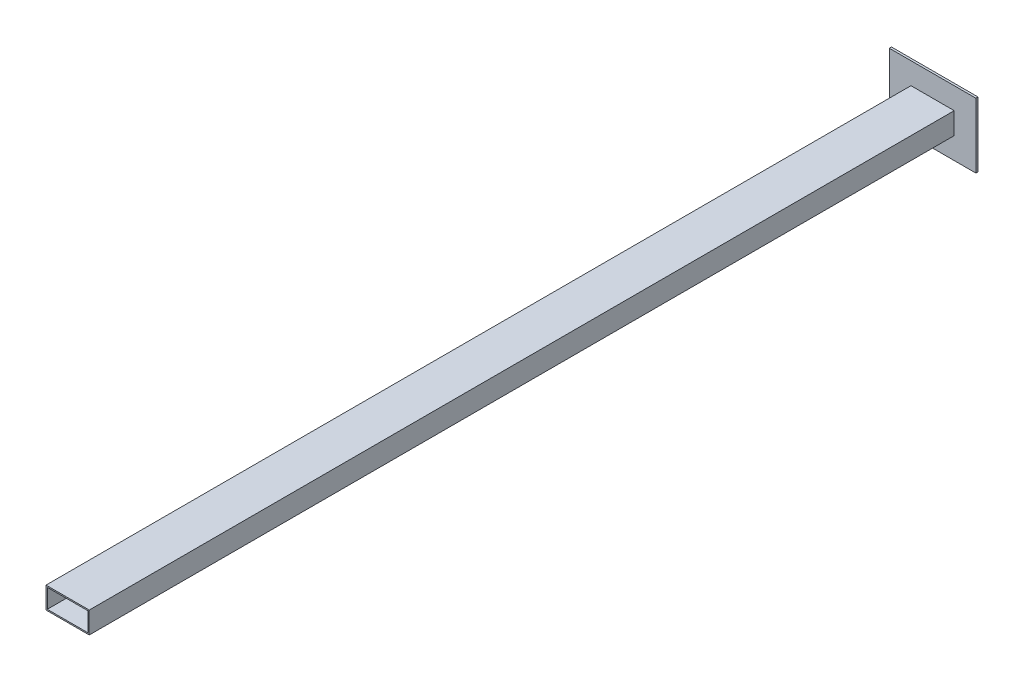
from build123d import *

# Parameters (mm, degrees)
SKETCH1_W              = 100
SKETCH1_H              = 50
SKETCH1_W_2            = 94
SKETCH1_H_2            = 44
BOSS_EXTRUDE1_DEPTH    = 2000
SKETCH2_W              = 200
SKETCH2_H              = 150
BOSS_EXTRUDE2_DEPTH    = 5
SPLIT2_SURFACE_1_BACK  = 2021.526
SPLIT2_SURFACE_1_DEPTH = 4043.052
SPLIT2_SURFACE_2_BACK  = 2021.526
SPLIT2_SURFACE_2_DEPTH = 4043.052


with BuildPart() as part:
    # Sketch1 → Boss-Extrude1 (new body)
    with BuildSketch(Plane.XY):
        with Locations((50, 25)):
            Rectangle(SKETCH1_W, SKETCH1_H)
        with Locations((50, 25)):
            Rectangle(SKETCH1_W_2, SKETCH1_H_2, mode=Mode.SUBTRACT)
    extrude(amount=BOSS_EXTRUDE1_DEPTH)

    # Sketch2 → Boss-Extrude2 (add)
    with BuildSketch(Plane(origin=(0, 0, 0), x_dir=(-1, 0, 0), z_dir=(0, 0, -1))):
        with Locations((-50, 25)):
            Rectangle(SKETCH2_W, SKETCH2_H)
    extrude(amount=BOSS_EXTRUDE2_DEPTH)


with BuildPart() as body_2:
    # Split2: the piece behind the surface
    add(part.part)
    # Split2 surface: a surface, the sketch's curves swept straight by 4043.052 mm
    with BuildLine(Plane.XZ.offset(-SPLIT2_SURFACE_1_BACK), mode=Mode.PRIVATE) as split2_surface_1_path:
        Line((-60.263801814, 0), (177.114806947, 0))
    split2_surface_1 = Shell.extrude(split2_surface_1_path.wire(), (0 * SPLIT2_SURFACE_1_DEPTH, -1 * SPLIT2_SURFACE_1_DEPTH, 0 * SPLIT2_SURFACE_1_DEPTH))
    split(bisect_by=split2_surface_1, keep=Keep.BOTTOM)


with BuildPart() as part_1:
    add(part.part)

    # Split2: split by a surface, the side it looks to stays
    # Split2 surface: a surface, the sketch's curves swept straight by 4043.052 mm
    with BuildLine(Plane.XZ.offset(-SPLIT2_SURFACE_2_BACK), mode=Mode.PRIVATE) as split2_surface_2_path:
        Line((-60.263801814, 0), (177.114806947, 0))
    split2_surface_2 = Shell.extrude(split2_surface_2_path.wire(), (0 * SPLIT2_SURFACE_2_DEPTH, -1 * SPLIT2_SURFACE_2_DEPTH, 0 * SPLIT2_SURFACE_2_DEPTH))
    split(bisect_by=split2_surface_2, keep=Keep.TOP)


solid = Compound([body_2.part, part_1.part])
